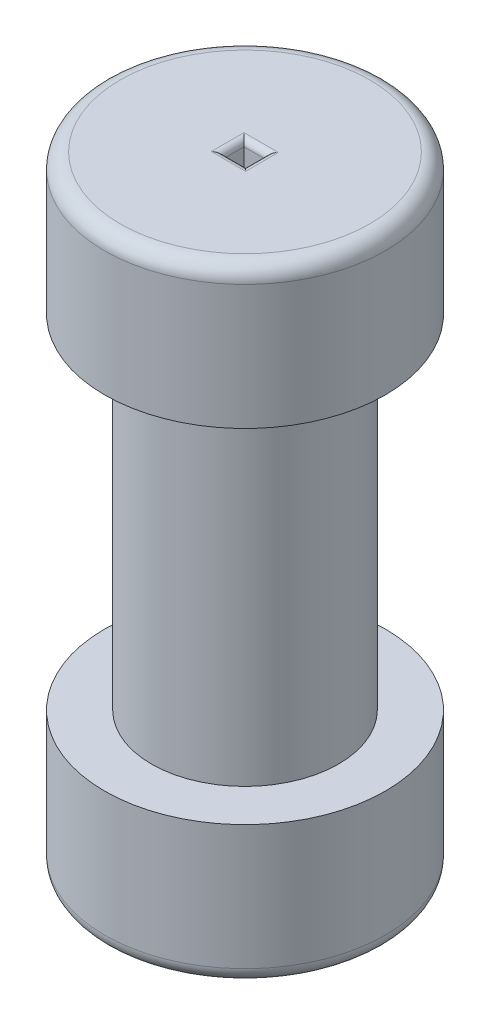
from build123d import *

# Parameters (mm, degrees)
SKETCH1_R           = 22.86
BOSS_EXTRUDE1_DEPTH = 22.86
SKETCH3_R           = 15.24
BOSS_EXTRUDE2_DEPTH = 55.88
SKETCH4_R           = 22.86
BOSS_EXTRUDE3_DEPTH = 22.86
FILLET3_R           = 2.54
CUT_EXTRUDE1_DEPTH  = 102.6
FILLET4_R           = 1


with BuildPart() as part:
    # Sketch1 → Boss-Extrude1 (new body)
    with BuildSketch(Plane(origin=(0, 0, 0), x_dir=(1, 0, 0), z_dir=(0, 1, 0))):
        Circle(SKETCH1_R)
    extrude(amount=BOSS_EXTRUDE1_DEPTH)

    # Sketch3 → Boss-Extrude2 (add)
    with BuildSketch(Plane(origin=(0, 22.86, 0), x_dir=(1, 0, 0), z_dir=(0, 1, 0))):
        Circle(SKETCH3_R)
    extrude(amount=BOSS_EXTRUDE2_DEPTH)

    # Sketch4 → Boss-Extrude3 (add)
    with BuildSketch(Plane(origin=(0, 78.74, 0), x_dir=(1, 0, 0), z_dir=(0, 1, 0))):
        Circle(SKETCH4_R)
    extrude(amount=BOSS_EXTRUDE3_DEPTH)

    # Fillet3
    fillet3_edges = [part.edges().sort_by_distance(p)[0] for p in [
        (-22.86, 101.6, 0),
        (-22.86, 0, 0),
    ]]
    fillet(fillet3_edges, radius=FILLET3_R)

    # Sketch5 → Cut-Extrude1 (cut, through all)
    with BuildSketch(Plane(origin=(0, 101.6, 0), x_dir=(1, 0, 0), z_dir=(0, 1, 0))):
        Polygon((-1.8, -0.03), (-1.8, -1.7), (1.8, -1.7), (1.8, 1.64), (-1.8, 1.64), align=None)
    extrude(amount=-CUT_EXTRUDE1_DEPTH, mode=Mode.SUBTRACT)

    # Fillet4
    fillet4_edges = [part.edges().sort_by_distance(p)[0] for p in [
        (0, 0, -1.64),
        (1.8, 0, 0.03),
        (0, 0, 1.7),
        (-1.8, 0, 0.03),
        (0, 101.6, -1.64),
        (-1.8, 101.6, 0.03),
        (0, 101.6, 1.7),
        (1.8, 101.6, 0.03),
    ]]
    fillet(fillet4_edges, radius=FILLET4_R)


solid = part.part
